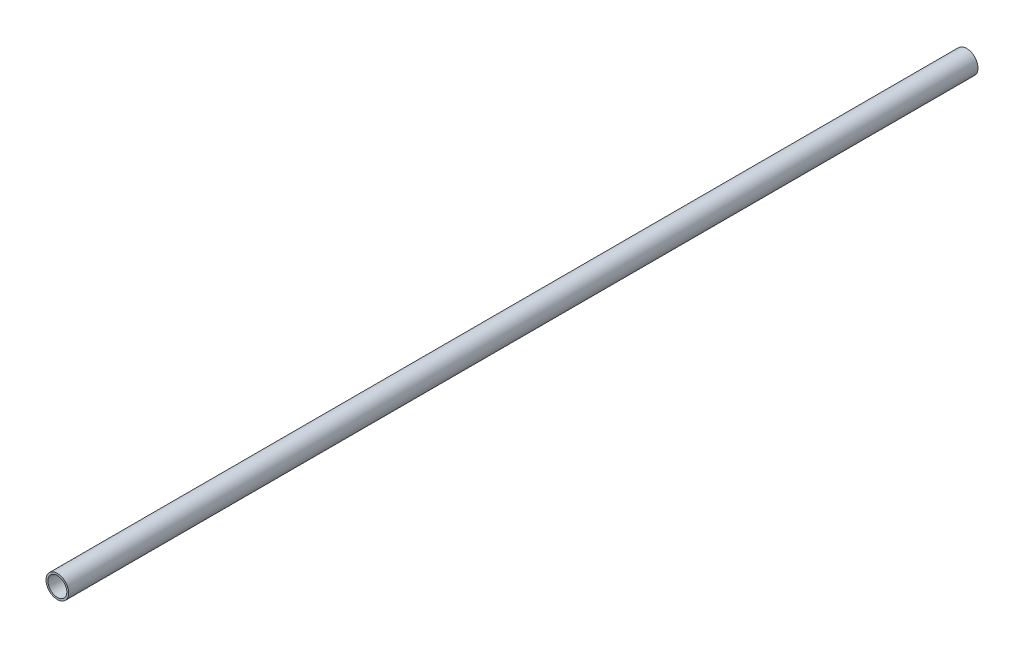
from build123d import *

# Parameters (mm, degrees)
SKETCH1_R           = 19.05
SKETCH1_R_2         = 15.875
BOSS_EXTRUDE1_DEPTH = 1524


with BuildPart() as part:
    # Sketch1 → Boss-Extrude1 (new body)
    with BuildSketch(Plane.XY):
        Circle(SKETCH1_R)
        Circle(SKETCH1_R_2, mode=Mode.SUBTRACT)
    extrude(amount=BOSS_EXTRUDE1_DEPTH)


solid = part.part
